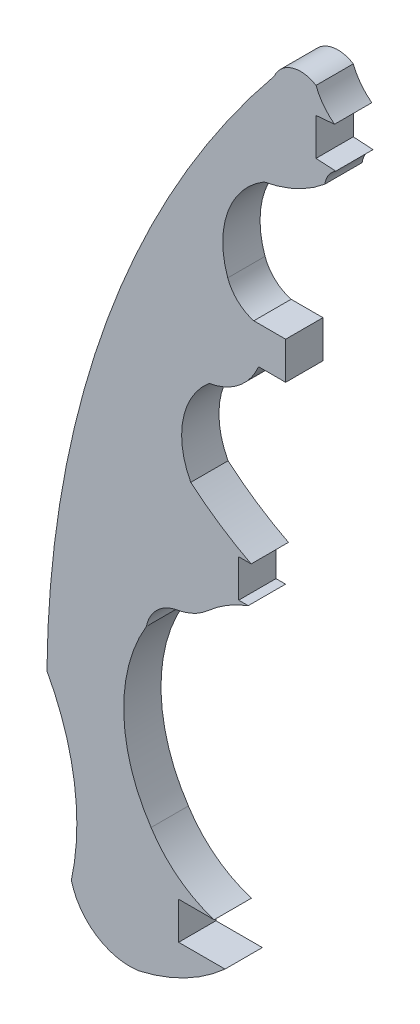
from build123d import *

# Parameters (mm, degrees)
BOSS_EXTRUDE1_DEPTH = 1.524


with BuildPart() as part:
    # Sketch1 → Boss-Extrude1 (new body)
    with BuildSketch(Plane.XY):
        with BuildLine():
            Line((-110.824360774, 0), (-110.824360774, -1.524))
            Line((-110.824360774, -1.524), (-108.927743626, -1.524))
            ThreePointArc((-108.927743626, -1.524), (-110.568786986, -2.659932295), (-112.442883949, -3.346318527))
            ThreePointArc((-112.442883949, -3.346318527), (-114.17716098, -2.968961004), (-115.207793415, -1.524))
            ThreePointArc((-115.207793415, -1.524), (-115.087103351, 2.021162801), (-116.205341733, 5.387509232))
            ThreePointArc((-116.205341733, 5.387509232), (-113.752453245, 19.026762394), (-106.916865485, 31.081663004))
            ThreePointArc((-106.916865485, 31.081663004), (-106.184950927, 31.736506317), (-105.211200263, 31.608723968))
            ThreePointArc((-105.211200263, 31.608723968), (-104.901513118, 31.0579276), (-104.454303839, 30.611512291))
            Line((-104.454303839, 30.611512291), (-105.211200263, 30.544825407))
            Line((-105.211200263, 30.544825407), (-105.211200263, 29.025368505))
            Line((-105.211200263, 29.025368505), (-104.403994808, 28.977437337))
            ThreePointArc((-104.403994808, 28.977437337), (-104.700603167, 28.683060455), (-104.849681876, 28.292663471))
            ThreePointArc((-104.849681876, 28.292663471), (-106.016123504, 27.550057971), (-107.333979522, 27.131364149))
            ThreePointArc((-107.333979522, 27.131364149), (-108.818673483, 25.32832607), (-108.817338403, 22.992676119))
            ThreePointArc((-108.817338403, 22.992676119), (-108.405188947, 22.369705182), (-107.752531072, 22.00639036))
            Line((-107.752531072, 22.00639036), (-106.451038151, 22.00639036))
            Line((-106.451038151, 22.00639036), (-106.451038151, 20.478701595))
            Line((-106.451038151, 20.478701595), (-107.557691458, 20.478701595))
            ThreePointArc((-107.557691458, 20.478701595), (-108.363599409, 19.419942847), (-109.579185571, 18.87882549))
            ThreePointArc((-109.579185571, 18.87882549), (-110.645223511, 17.073742216), (-110.328866367, 15.001381081))
            ThreePointArc((-110.328866367, 15.001381081), (-109.142498989, 14.103916539), (-107.861232511, 13.348094888))
            Line((-107.861232511, 13.348094888), (-108.369232511, 13.348094888))
            Line((-108.369232511, 13.348094888), (-108.369232511, 11.811176348))
            Line((-108.369232511, 11.811176348), (-107.979675981, 11.811176348))
            ThreePointArc((-107.979675981, 11.811176348), (-108.849411149, 11.386044546), (-109.628173595, 10.810974668))
            ThreePointArc((-109.628173595, 10.810974668), (-110.216954925, 10.419220775), (-110.890927129, 10.204987173))
            ThreePointArc((-110.890927129, 10.204987173), (-111.704771273, 9.793399538), (-112.1438695, 8.994062677))
            ThreePointArc((-112.1438695, 8.994062677), (-113.066844869, 5.45696931), (-111.950245848, 1.976147619))
            ThreePointArc((-111.950245848, 1.976147619), (-110.838027473, 0.758299628), (-109.373389254, 0))
            Line((-109.373389254, 0), (-110.824360774, 0))
        make_face()
    extrude(amount=BOSS_EXTRUDE1_DEPTH)


solid = part.part
